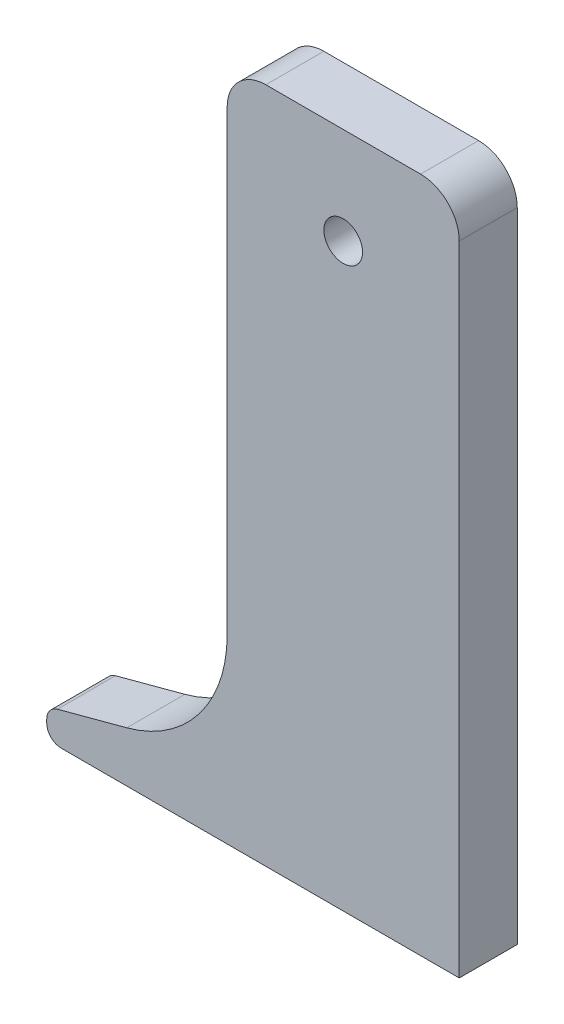
from build123d import *

# Parameters (mm, degrees)
BOSS_EXTRUDE1_DEPTH     = 3
SKETCH2_R               = 1
CUT_EXTRUDE1_DEPTH      = 1
CUT_EXTRUDE1_DEPTH_BACK = 4


with BuildPart() as part:
    # Sketch1 → Boss-Extrude1 (new body)
    with BuildSketch(Plane.XY):
        with BuildLine():
            Line((-6, -30), (-14.580127019, -30))
            ThreePointArc((-14.580127019, -30), (-15.110457105, -29.780330086), (-15.330127019, -29.25))
            Line((-15.330127019, -29.25), (-15.330127019, -29.075495241))
            ThreePointArc((-15.330127019, -29.075495241), (-15.175142024, -28.618924169), (-14.774241303, -28.351050871))
            Line((-14.774241303, -28.351050871), (-11.188266684, -27.390191868))
            ThreePointArc((-11.188266684, -27.390191868), (-7.446526618, -24.890041087), (-6, -20.628711084))
            Line((-6, -20.628711084), (-6, 0))
            Line((-6, 0), (-6, 3))
            ThreePointArc((-6, 3), (-5.414213562, 4.414213562), (-4, 5))
            Line((-4, 5), (4, 5))
            ThreePointArc((4, 5), (5.414213562, 4.414213562), (6, 3))
            Line((6, 3), (6, 0))
            Line((6, 0), (6, -30))
            Line((6, -30), (-6, -30))
        make_face()
    extrude(amount=BOSS_EXTRUDE1_DEPTH)

    # Sketch2 → Cut-Extrude1 (cut, two sides)
    with BuildSketch(Plane.XY.offset(3)) as cut_extrude1_sk:
        Circle(SKETCH2_R)
    extrude(amount=CUT_EXTRUDE1_DEPTH, mode=Mode.SUBTRACT)
    extrude(cut_extrude1_sk.sketch, amount=-CUT_EXTRUDE1_DEPTH_BACK, mode=Mode.SUBTRACT)


solid = part.part
